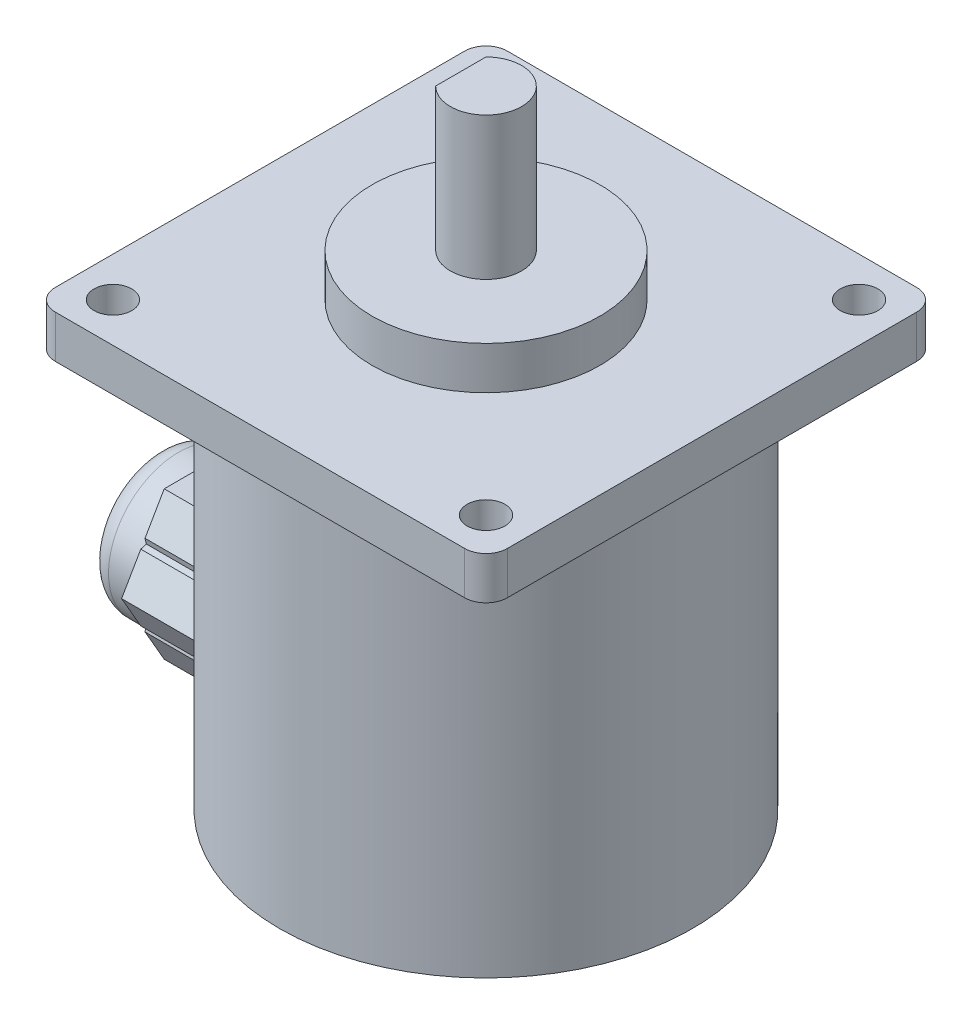
from build123d import *

# Parameters (mm, degrees)
BOSS_EXTRUDE1_DEPTH      = 32
SKETCH1_3_R              = 16
BOSS_EXTRUDE2_DEPTH      = 12
SKETCH1_4_R              = 2.65
SKETCH1_4_R_2            = 16
BOSS_EXTRUDE3_DEPTH      = 6
SKETCH1_5_R              = 29
BOSS_EXTRUDE4_DEPTH      = 56
BOSS_EXTRUDE5_DEPTH      = 12
BOSS_EXTRUDE5_DEPTH_BACK = 5
SKETCH3_R                = 9.808050829
BOSS_EXTRUDE6_DEPTH      = 7
FILLET1_R                = 3


with BuildPart() as part:
    # Sketch1 → Boss-Extrude1 (new body)
    with BuildSketch(Plane(origin=(0, 0, 0), x_dir=(1, 0, 0), z_dir=(0, 1, 0))):
        with BuildLine():
            Line((-3.535533906, 3.535533906), (-3.535533906, -3.535533906))
            ThreePointArc((-3.535533906, -3.535533906), (1.913417162, -4.619397663), (5, 0))
            ThreePointArc((5, 0), (1.913417162, 4.619397663), (-3.535533906, 3.535533906))
        make_face()
    extrude(amount=BOSS_EXTRUDE1_DEPTH)

    # Sketch1_3 → Boss-Extrude2 (add)
    with BuildSketch(Plane(origin=(0, 0, 0), x_dir=(1, 0, 0), z_dir=(0, 1, 0))):
        Circle(SKETCH1_3_R)
        with BuildLine():
            Line((-3.535533906, -3.535533906), (-3.535533906, 3.535533906))
            ThreePointArc((-3.535533906, 3.535533906), (5, 0), (-3.535533906, -3.535533906))
        make_face(mode=Mode.SUBTRACT)
    extrude(amount=BOSS_EXTRUDE2_DEPTH)

    # Sketch1_4 → Boss-Extrude3 (add)
    with BuildSketch(Plane(origin=(0, 0, 0), x_dir=(1, 0, 0), z_dir=(0, 1, 0))):
        with BuildLine():
            Line((28.75, 31.75), (-28.75, 31.75))
            ThreePointArc((-28.75, 31.75), (-30.871320344, 30.871320344), (-31.75, 28.75))
            Line((-31.75, 28.75), (-31.75, -28.75))
            ThreePointArc((-31.75, -28.75), (-30.871320344, -30.871320344), (-28.75, -31.75))
            Line((-28.75, -31.75), (28.75, -31.75))
            ThreePointArc((28.75, -31.75), (30.871320344, -30.871320344), (31.75, -28.75))
            Line((31.75, -28.75), (31.75, 28.75))
            ThreePointArc((31.75, 28.75), (30.871320344, 30.871320344), (28.75, 31.75))
        make_face()
        with Locations((-26.2, -26.2)):
            Circle(SKETCH1_4_R, mode=Mode.SUBTRACT)
        with Locations((26.2, -26.2)):
            Circle(SKETCH1_4_R, mode=Mode.SUBTRACT)
        with Locations((-26.2, 26.2)):
            Circle(SKETCH1_4_R, mode=Mode.SUBTRACT)
        with Locations((26.2, 26.2)):
            Circle(SKETCH1_4_R, mode=Mode.SUBTRACT)
        Circle(SKETCH1_4_R_2, mode=Mode.SUBTRACT)
    extrude(amount=BOSS_EXTRUDE3_DEPTH)

    # Sketch1_5 → Boss-Extrude4 (add)
    with BuildSketch(Plane(origin=(0, 0, 0), x_dir=(1, 0, 0), z_dir=(0, 1, 0))):
        Circle(SKETCH1_5_R)
    extrude(amount=-BOSS_EXTRUDE4_DEPTH)

    # Sketch2 → Boss-Extrude5 (add, two sides: drawn at the far end of the back side and taken through both)
    with BuildSketch(Plane.ZY.offset(28.869533834).offset(-BOSS_EXTRUDE5_DEPTH_BACK)):
        Polygon((-1.063399037, -56), (4.330127019, -56), (7.026890047, -51.32906942), (6.838640743, -50.536822393), (7.618871446, -50.303727559), (10.315634474, -45.632796979), (7.618871446, -40.961866399), (6.838640743, -40.728771565), (7.026890047, -39.936524538), (4.330127019, -35.265593958), (-1.063399037, -35.265593958), (-1.655380436, -35.82474615), (-2.247361835, -35.265593958), (-7.640887891, -35.265593958), (-10.337650919, -39.936524538), (-10.149401615, -40.728771565), (-10.929632318, -40.961866399), (-13.626395346, -45.632796979), (-10.929632318, -50.303727559), (-10.149401615, -50.536822393), (-10.337650919, -51.32906942), (-7.640887891, -56), (-2.247361835, -56), (-1.655380436, -55.440847807), align=None)
    extrude(amount=BOSS_EXTRUDE5_DEPTH + BOSS_EXTRUDE5_DEPTH_BACK)

    # Sketch3 → Boss-Extrude6 (add)
    with BuildSketch(Plane.ZY.offset(40.869533834)):
        with Locations((-1.655380436, -45.632796979)):
            Circle(SKETCH3_R)
    extrude(amount=BOSS_EXTRUDE6_DEPTH)

    # Fillet1
    fillet1_edges = [part.edges().sort_by_distance(p)[0] for p in [
        (-47.869533834, -45.632796979, -11.463431265),
    ]]
    fillet(fillet1_edges, radius=FILLET1_R)


solid = part.part
